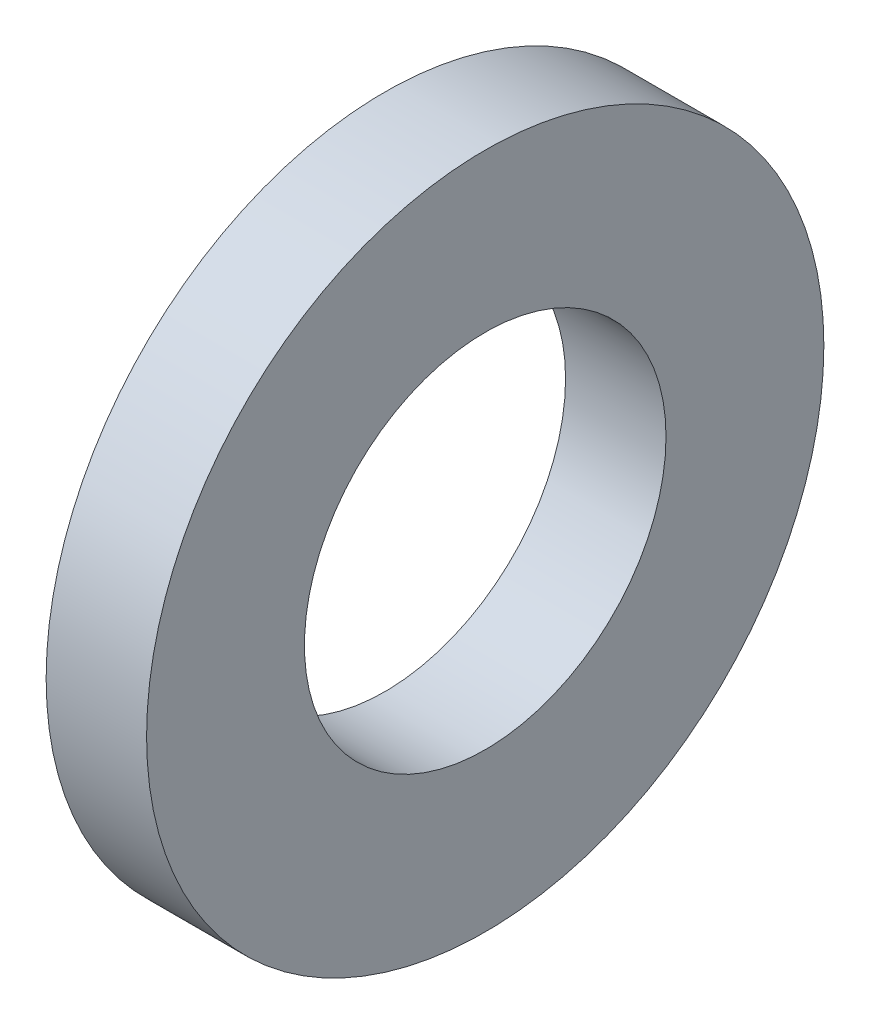
from build123d import *

# Parameters (mm, degrees)
SKETCH1_R           = 5.9944
SKETCH1_R_2         = 3.2004
BOSS_EXTRUDE1_DEPTH = 1.778


with BuildPart() as part:
    # Sketch1 → Boss-Extrude1 (new body)
    with BuildSketch(Plane(origin=(0, 0, 0), x_dir=(0, 0, -1), z_dir=(1, 0, 0))):
        Circle(SKETCH1_R)
        Circle(SKETCH1_R_2, mode=Mode.SUBTRACT)
    extrude(amount=BOSS_EXTRUDE1_DEPTH)


solid = part.part
